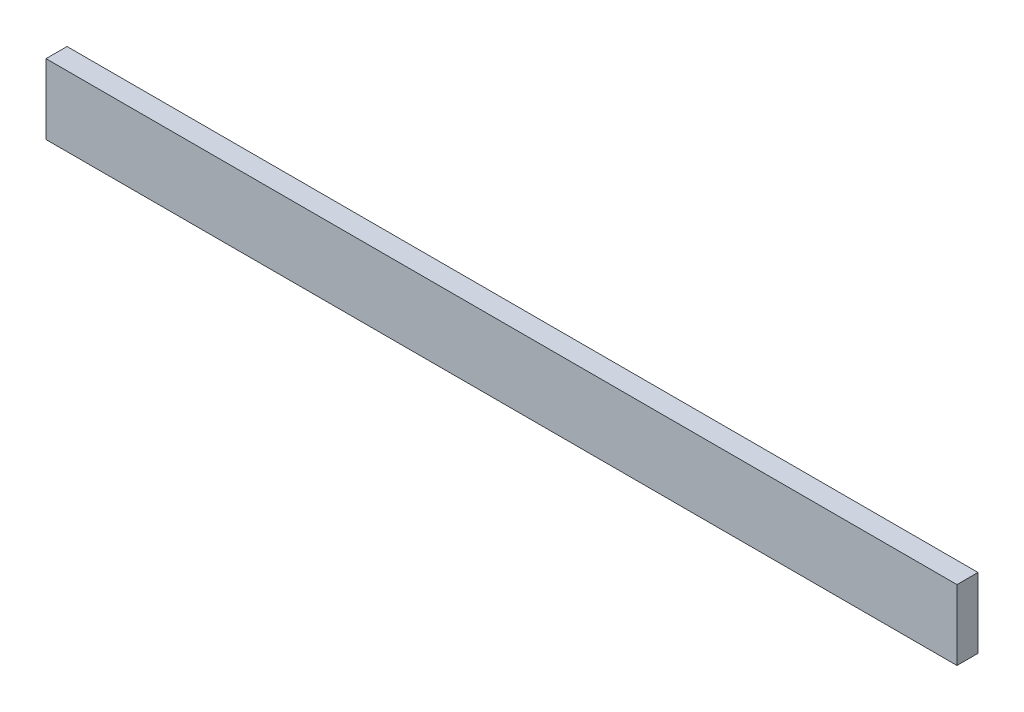
from build123d import *

# Parameters (mm, degrees)
ESBO_O1_W                = 130
ESBO_O1_H                = 10
RESSALTO_EXTRUS_O3_DEPTH = 3


with BuildPart() as part:
    # Esboço1 → Ressalto-extrusão3 (new body)
    with BuildSketch(Plane.XY):
        with Locations((-7.107871181, -5)):
            Rectangle(ESBO_O1_W, ESBO_O1_H)
    extrude(amount=RESSALTO_EXTRUS_O3_DEPTH)


solid = part.part
